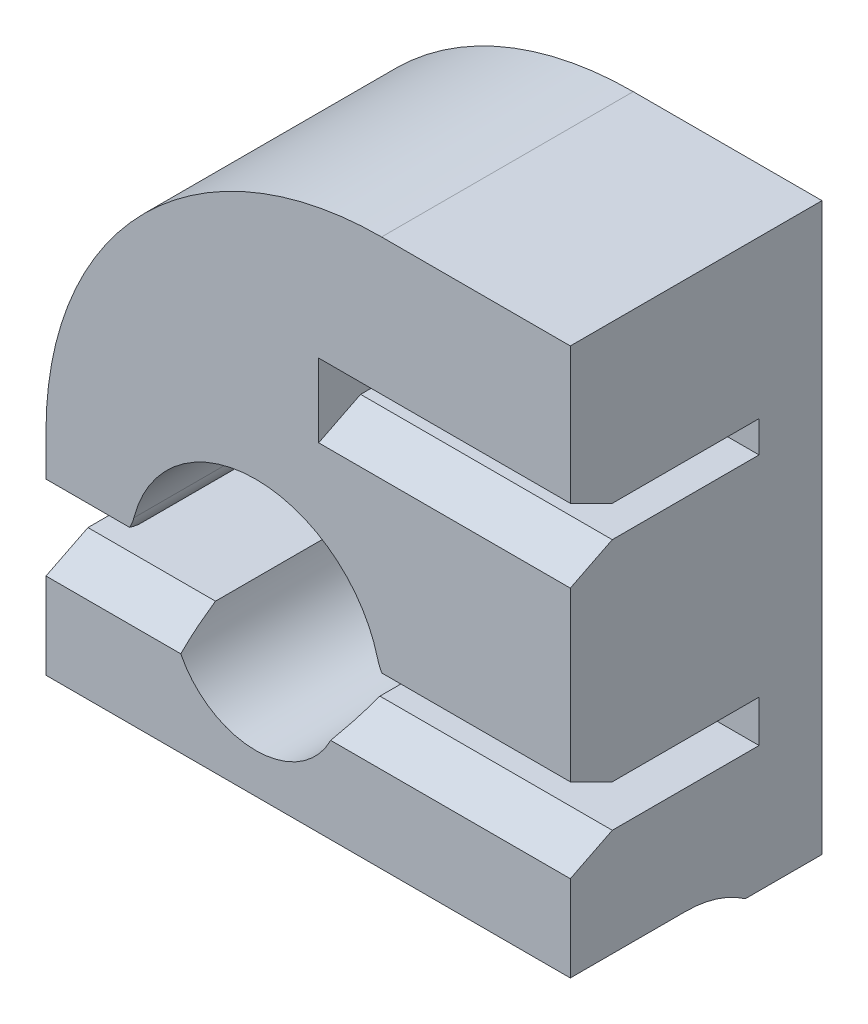
from build123d import *

# Parameters (mm, degrees)
SKETCH1_W           = 25
SKETCH1_H           = 27
BOSS_EXTRUDE1_DEPTH = 12
CUT_EXTRUDE1_DEPTH  = 9
CUT_EXTRUDE2_DEPTH  = 26
FILLET1_R           = 16
CHAMFER2_SIZE       = 1
CHAMFER2_SIZE2      = 2
CHAMFER3_SIZE       = 1
CHAMFER3_SIZE2      = 2
CUT_EXTRUDE4_DEPTH  = 12
FILLET2_R           = 2
SKETCH6_R           = 4
CUT_EXTRUDE5_DEPTH  = 10


with BuildPart() as part:
    # Sketch1 → Boss-Extrude1 (new body)
    with BuildSketch(Plane.XY):
        with Locations((-12.5, 7.5)):
            Rectangle(SKETCH1_W, SKETCH1_H)
    extrude(amount=BOSS_EXTRUDE1_DEPTH)

    # Sketch2 → Cut-Extrude1 (cut)
    with BuildSketch(Plane.XY.offset(12)):
        with BuildLine():
            Line((0, 0), (-25, 0))
            Line((-25, 0), (-25, 2))
            Line((-25, 2), (-21, 2))
            ThreePointArc((-21, 2), (-15, 8), (-9, 2))
            Line((-9, 2), (0, 2))
            Line((0, 2), (0, 0))
        make_face()
        Polygon((0, 12), (-12, 12), (-12, 13.5), (-9.096, 13.5), (-8.596, 13), (-8.096, 13), (-7.596, 13.5), (-7.064, 13.5), (-6.564, 13), (-6.064, 13), (-5.564, 13.5), (-5.032, 13.5), (-4.532, 13), (-4.032, 13), (-3.532, 13.5), (-3, 13.5), (-2.5, 13), (-2, 13), (-1.5, 13.5), (0, 13.5), align=None)
    extrude(amount=-CUT_EXTRUDE1_DEPTH, mode=Mode.SUBTRACT)

    # Sketch3 → Cut-Extrude2 (cut, through all)
    with BuildSketch(Plane(origin=(0, 0, 0), x_dir=(0, 0, -1), z_dir=(1, 0, 0))):
        with BuildLine():
            Line((-6.5, -5.1), (-14.907534026, -5.1))
            Line((-14.907534026, -5.1), (-14.907534026, -15))
            Line((-14.907534026, -15), (-6.5, -15))
            ThreePointArc((-6.5, -15), (-1.55, -10.05), (-6.5, -5.1))
        make_face()
    extrude(amount=-CUT_EXTRUDE2_DEPTH, mode=Mode.SUBTRACT)

    # Fillet1
    fillet1_edges = [part.edges().sort_by_distance(p)[0] for p in [
        (-25, 21, 6),
    ]]
    fillet(fillet1_edges, radius=FILLET1_R)

    # Chamfer2
    chamfer2_edges = [part.edges().sort_by_distance(p)[0] for p in [
        (-4.5, 2, 12),
        (-23, 2, 12),
    ]]
    chamfer2_side = [part.faces().sort_by_distance(p)[0] for p in [
        (-10.97729814, 11.640214696, 12),
    ]]
    chamfer(chamfer2_edges, length=CHAMFER2_SIZE, length2=CHAMFER2_SIZE2, reference=chamfer2_side[0])

    # Chamfer3
    chamfer3_edges = [part.edges().sort_by_distance(p)[0] for p in [
        (-12.5, 0, 12),
    ]]
    chamfer3_side = [part.faces().sort_by_distance(p)[0] for p in [
        (-12.5, -2.55, 12),
    ]]
    chamfer(chamfer3_edges, length=CHAMFER3_SIZE, length2=CHAMFER3_SIZE2, reference=chamfer3_side[0])

    # Sketch5 → Cut-Extrude4 (cut)
    with BuildSketch(Plane(origin=(0, 0, 0), x_dir=(0, 0, -1), z_dir=(1, 0, 0))):
        Polygon((-12, 14.5), (-8.5, 12.75), (-12, 11), (-12, 12), (-12, 13.5), align=None)
    extrude(amount=-CUT_EXTRUDE4_DEPTH, mode=Mode.SUBTRACT)

    # Fillet2
    fillet2_edges = [part.edges().sort_by_distance(p)[0] for p in [
        (-9, 2, 6.5),
        (-21, 2, 6.5),
    ]]
    fillet(fillet2_edges, radius=FILLET2_R)

    # Sketch6 → Cut-Extrude5 (cut)
    with BuildSketch(Plane.XY.offset(12)):
        with Locations((-15, 0.794645258)):
            Circle(SKETCH6_R)
    extrude(amount=-CUT_EXTRUDE5_DEPTH, mode=Mode.SUBTRACT)


solid = part.part
